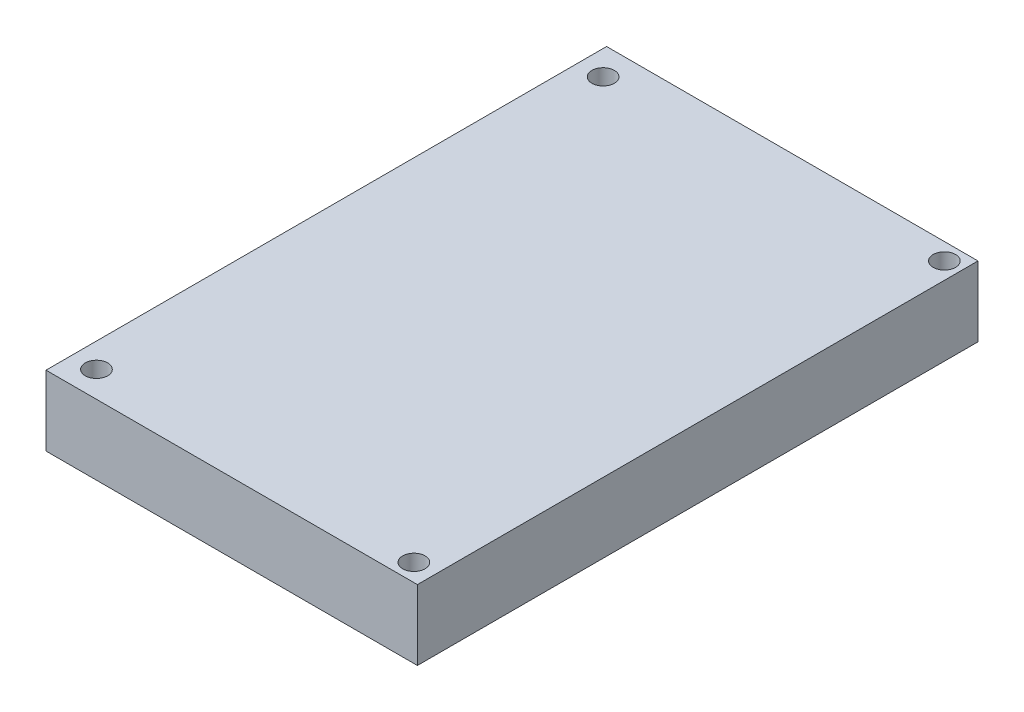
from build123d import *

# Parameters (mm, degrees)
SKETCH1_W           = 53
SKETCH1_H           = 80
SKETCH1_R           = 1.6
BOSS_EXTRUDE1_DEPTH = 10


with BuildPart() as part:
    # Sketch1 → Boss-Extrude1 (new body)
    with BuildSketch(Plane(origin=(0, 0, 0), x_dir=(1, 0, 0), z_dir=(0, 1, 0))):
        Rectangle(SKETCH1_W, SKETCH1_H)
        with Locations((-23, 36)):
            Circle(SKETCH1_R, mode=Mode.SUBTRACT)
        with Locations((24.1, 37.6)):
            Circle(SKETCH1_R, mode=Mode.SUBTRACT)
        with Locations((23.5, -37.5)):
            Circle(SKETCH1_R, mode=Mode.SUBTRACT)
        with Locations((-23, -36.3)):
            Circle(SKETCH1_R, mode=Mode.SUBTRACT)
    extrude(amount=BOSS_EXTRUDE1_DEPTH)


solid = part.part
